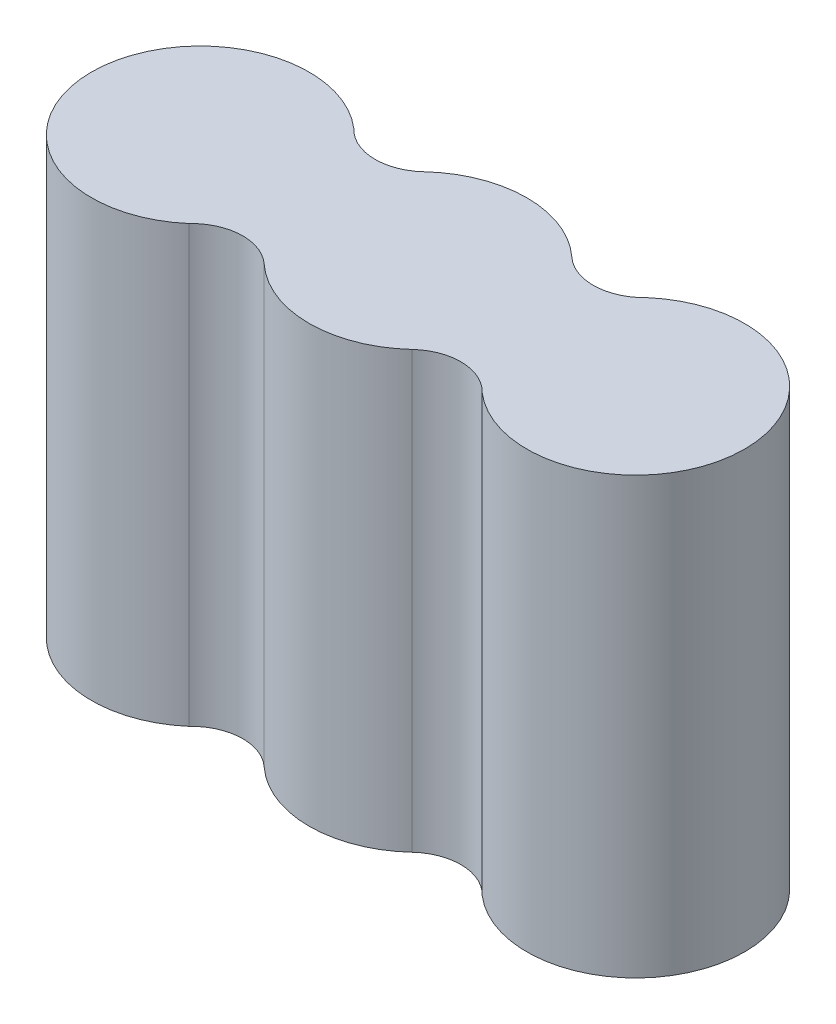
from build123d import *

# Parameters (mm, degrees)
SALIENTE_EXTRUIR1_DEPTH = 30


with BuildPart() as part:
    # Croquis1 → Saliente-Extruir1 (new body)
    with BuildSketch(Plane(origin=(0, 0, 0), x_dir=(1, 0, 0), z_dir=(0, 1, 0))):
        with BuildLine():
            ThreePointArc((5.093864637, 5.504774569), (0, 7.5), (-5.093864637, 5.504774569))
            ThreePointArc((-5.093864637, 5.504774569), (-7.629622361, 4.56075577), (-10.095654419, 5.674274793))
            ThreePointArc((-10.095654419, 5.674274793), (-22.5, 0), (-10.095654419, -5.674274793))
            ThreePointArc((-10.095654419, -5.674274793), (-7.629622361, -4.56075577), (-5.093864637, -5.504774569))
            ThreePointArc((-5.093864637, -5.504774569), (0, -7.5), (5.093864637, -5.504774569))
            ThreePointArc((5.093864637, -5.504774569), (7.629622361, -4.56075577), (10.095654419, -5.674274793))
            ThreePointArc((10.095654419, -5.674274793), (22.5, 0), (10.095654419, 5.674274793))
            ThreePointArc((10.095654419, 5.674274793), (7.629622361, 4.56075577), (5.093864637, 5.504774569))
        make_face()
    extrude(amount=SALIENTE_EXTRUIR1_DEPTH)


solid = part.part
